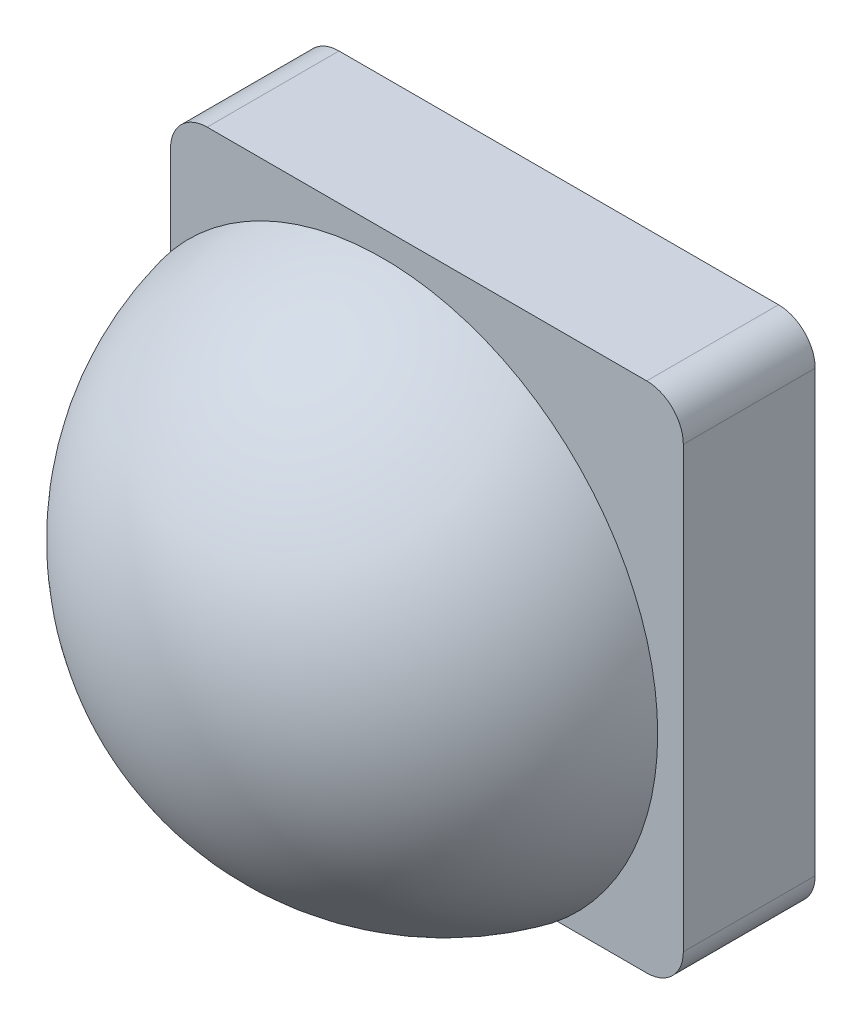
from build123d import *

# Parameters (mm, degrees)
AUFSATZ_LINEAR_AUSTRAGEN1_DEPTH = 18
WANDUNG1_T                      = -2
SKIZZE2_R                       = 17.5
AUFSATZ_LINEAR_AUSTRAGEN2_DEPTH = 6


with BuildPart() as part:
    # Skizze1 → Aufsatz-Linear austragen1 (new body)
    with BuildSketch(Plane.XY):
        with BuildLine():
            Line((-30, -35), (30, -35))
            ThreePointArc((30, -35), (33.535533906, -33.535533906), (35, -30))
            Line((35, -30), (35, 30))
            ThreePointArc((35, 30), (33.535533906, 33.535533906), (30, 35))
            Line((30, 35), (-30, 35))
            ThreePointArc((-30, 35), (-33.535533906, 33.535533906), (-35, 30))
            Line((-35, 30), (-35, -30))
            ThreePointArc((-35, -30), (-33.535533906, -33.535533906), (-30, -35))
        make_face()
    extrude(amount=AUFSATZ_LINEAR_AUSTRAGEN1_DEPTH)

    # Wandung1
    wandung1_openings = [part.faces().sort_by_distance(p)[0] for p in [
        (0, 0, 0),
    ]]
    offset(amount=WANDUNG1_T, openings=wandung1_openings, kind=Kind.INTERSECTION)

    # Skizze2 → Aufsatz-Linear austragen2 (add)
    with BuildSketch(Plane.XY.offset(18)):
        Circle(SKIZZE2_R)
    extrude(amount=AUFSATZ_LINEAR_AUSTRAGEN2_DEPTH)

    # Skizze3 → Rotation1 (revolve)
    with BuildSketch(Plane(origin=(0, 0, 0), x_dir=(1, 0, 0), z_dir=(0, 1, 0))):
        with BuildLine():
            Line((0, -24), (37.5, -24))
            ThreePointArc((37.5, -24), (24.01171589, -45.577144863), (0, -54))
            Line((0, -54), (0, -24))
        make_face()
    revolve(axis=Axis((0, 0, -8.721924789), (0, 0, 1)))


solid = part.part
